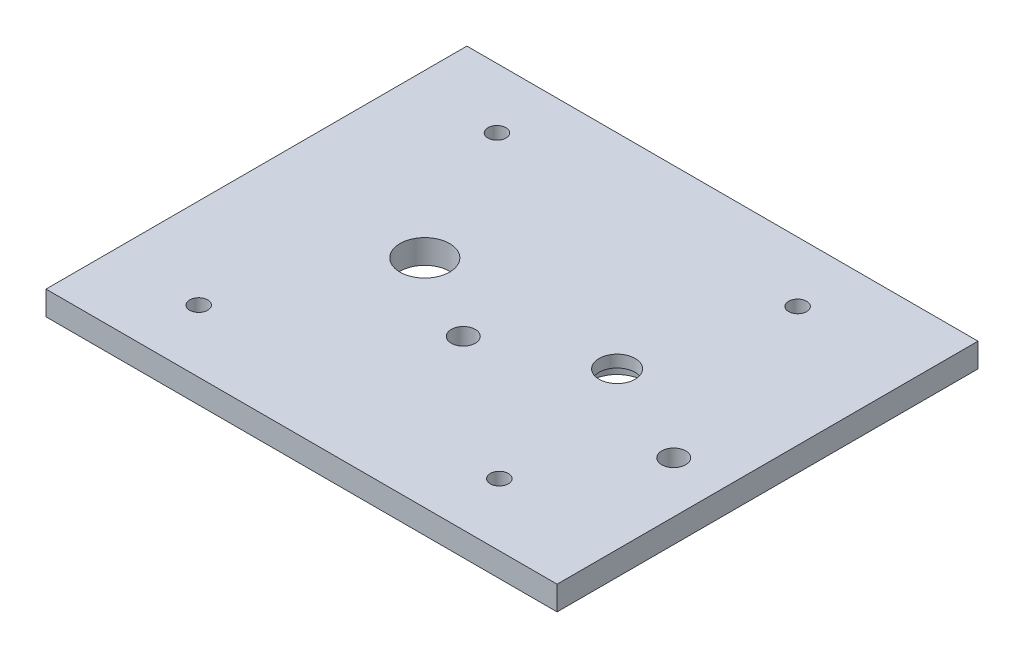
from build123d import *

# Parameters (mm, degrees)
SKETCH1_W           = 85
SKETCH1_H           = 70
SKETCH1_R           = 1.5
SKETCH1_R_2         = 2
SKETCH1_R_3         = 4.125
SKETCH1_R_4         = 3
BOSS_EXTRUDE4_DEPTH = 4
SKETCH1_7_R         = 4.5
CUT_EXTRUDE2_DEPTH  = 2


with BuildPart() as part:
    # Sketch1 → Boss-Extrude4 (new body)
    with BuildSketch(Plane(origin=(0, 0, 0), x_dir=(1, 0, 0), z_dir=(0, 1, 0))):
        Rectangle(SKETCH1_W, SKETCH1_H)
        with Locations((-27.5, -24.60667729)):
            Circle(SKETCH1_R, mode=Mode.SUBTRACT)
        with Locations((22.5, -24.60667729)):
            Circle(SKETCH1_R, mode=Mode.SUBTRACT)
        with Locations((34, -7.102660735)):
            Circle(SKETCH1_R_2, mode=Mode.SUBTRACT)
        with Locations((-27.5, 25)):
            Circle(SKETCH1_R, mode=Mode.SUBTRACT)
        with Locations((22.5, 25)):
            Circle(SKETCH1_R, mode=Mode.SUBTRACT)
        with Locations((-15.5, 1)):
            Circle(SKETCH1_R_3, mode=Mode.SUBTRACT)
        with Locations((-1, -7.102660735)):
            Circle(SKETCH1_R_2, mode=Mode.SUBTRACT)
        with Locations((16.478339488, 0.999882702)):
            Circle(SKETCH1_R_4, mode=Mode.SUBTRACT)
    extrude(amount=BOSS_EXTRUDE4_DEPTH)

    # Sketch1_7 → Cut-Extrude2 (cut)
    with BuildSketch(Plane(origin=(0, 0, 0), x_dir=(1, 0, 0), z_dir=(0, 1, 0))):
        with Locations((16.478339488, 0.999882702)):
            Circle(SKETCH1_7_R)
    extrude(amount=CUT_EXTRUDE2_DEPTH, mode=Mode.SUBTRACT)


solid = part.part
